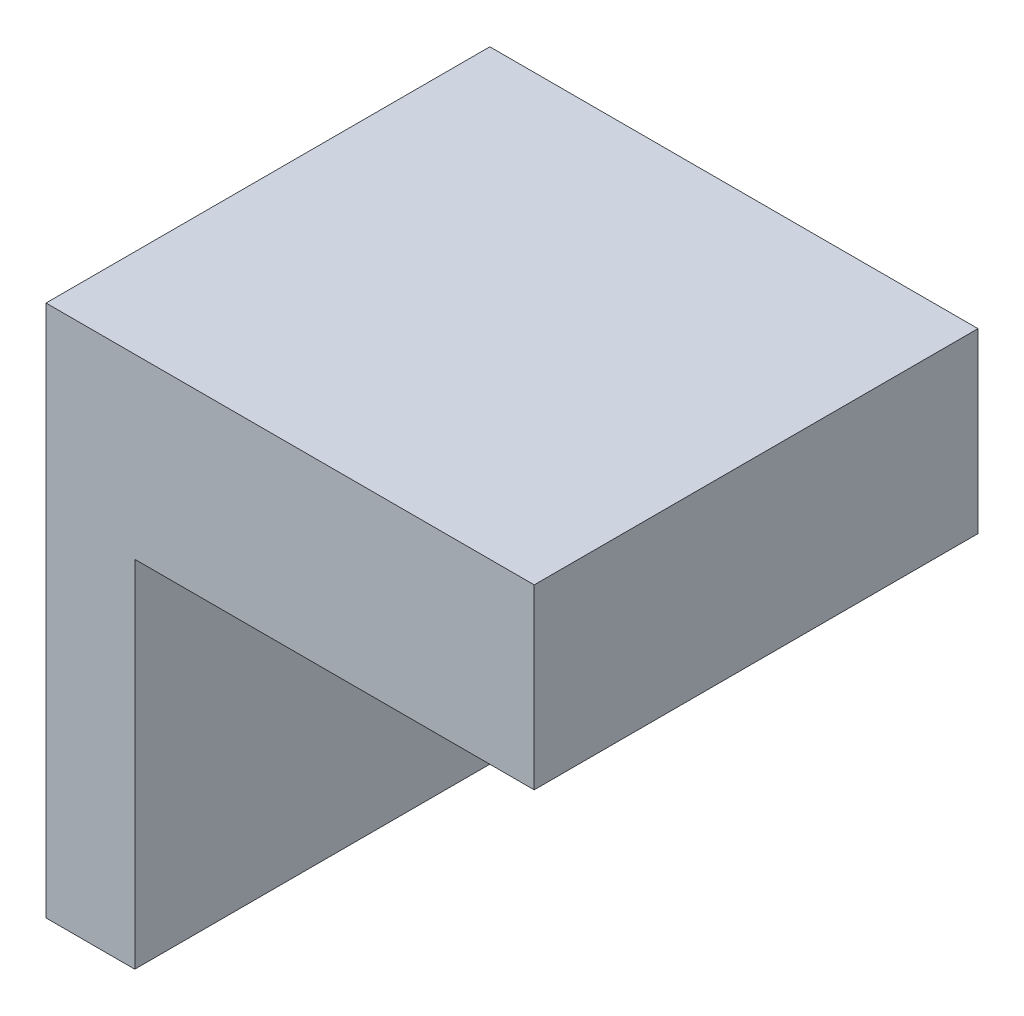
from build123d import *

# Parameters (mm, degrees)
SALIENTE_EXTRUIR1_DEPTH                        = 50
PERFORADOR_PARA_ROSCAR_PARA_MACHO_DE_ROS_D     = 5
PERFORADOR_PARA_ROSCAR_PARA_MACHO_DE_ROS_DEPTH = 11
PERFORADOR_PARA_ROSCAR_PARA_MACHO_DE_ROS_TIP   = 1.502151548


with BuildPart() as part:
    # Croquis1 → Saliente-Extruir1 (new body)
    with BuildSketch(Plane.XY):
        Polygon((-42.31300039, -15.146269262), (12.68699961, -15.146269262), (12.68699961, -35.146269262), (-32.31300039, -35.146269262), (-32.31300039, -75.146269262), (-42.31300039, -75.146269262), align=None)
    extrude(amount=SALIENTE_EXTRUIR1_DEPTH)

    # Perforador para roscar para macho de roscar para M6x1.01
    with Locations(Plane(origin=(-32.31300039, -55.146269262, 25), x_dir=(0, 0, 1), z_dir=(1, 0, 0))):
        with Locations((0, 0)):
            Hole(PERFORADOR_PARA_ROSCAR_PARA_MACHO_DE_ROS_D / 2, depth=PERFORADOR_PARA_ROSCAR_PARA_MACHO_DE_ROS_DEPTH)
            with Locations((0, 0, -(PERFORADOR_PARA_ROSCAR_PARA_MACHO_DE_ROS_DEPTH + PERFORADOR_PARA_ROSCAR_PARA_MACHO_DE_ROS_TIP / 2))):  # 118° drill point
                Cone(0, PERFORADOR_PARA_ROSCAR_PARA_MACHO_DE_ROS_D / 2, PERFORADOR_PARA_ROSCAR_PARA_MACHO_DE_ROS_TIP, mode=Mode.SUBTRACT)


solid = part.part
